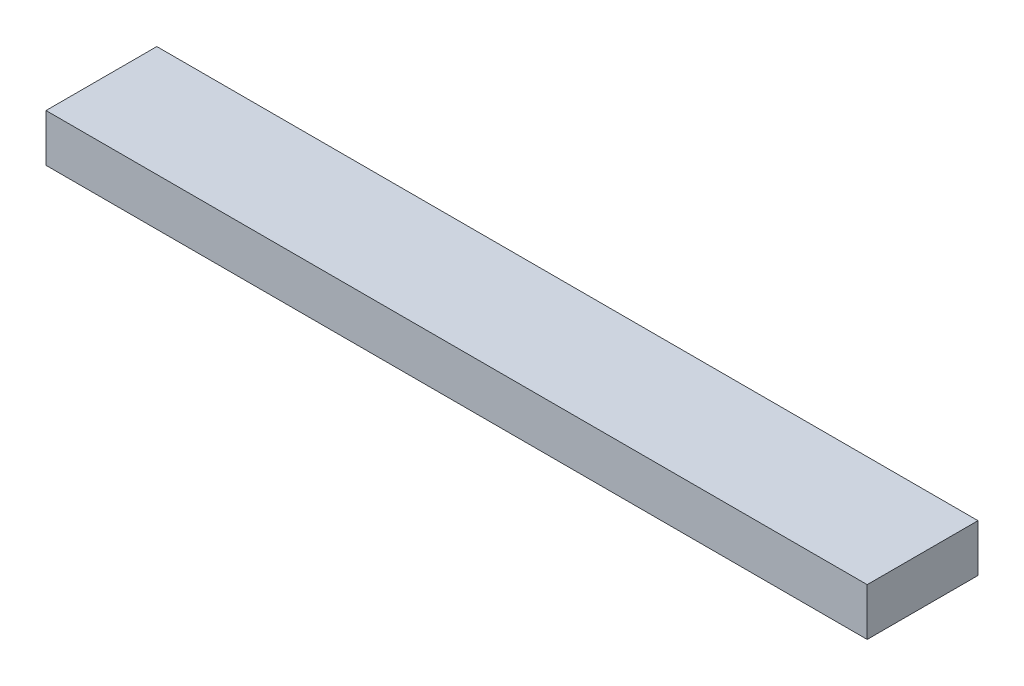
from build123d import *

# Parameters (mm, degrees)
SKETCH1_W           = 658.8125
SKETCH1_H           = 88.9
BOSS_EXTRUDE1_DEPTH = 38.1


with BuildPart() as part:
    # Sketch1 → Boss-Extrude1 (new body)
    with BuildSketch(Plane(origin=(0, 0, 0), x_dir=(1, 0, 0), z_dir=(0, 1, 0))):
        with Locations((329.40625, 44.45)):
            Rectangle(SKETCH1_W, SKETCH1_H)
    extrude(amount=BOSS_EXTRUDE1_DEPTH)


solid = part.part
